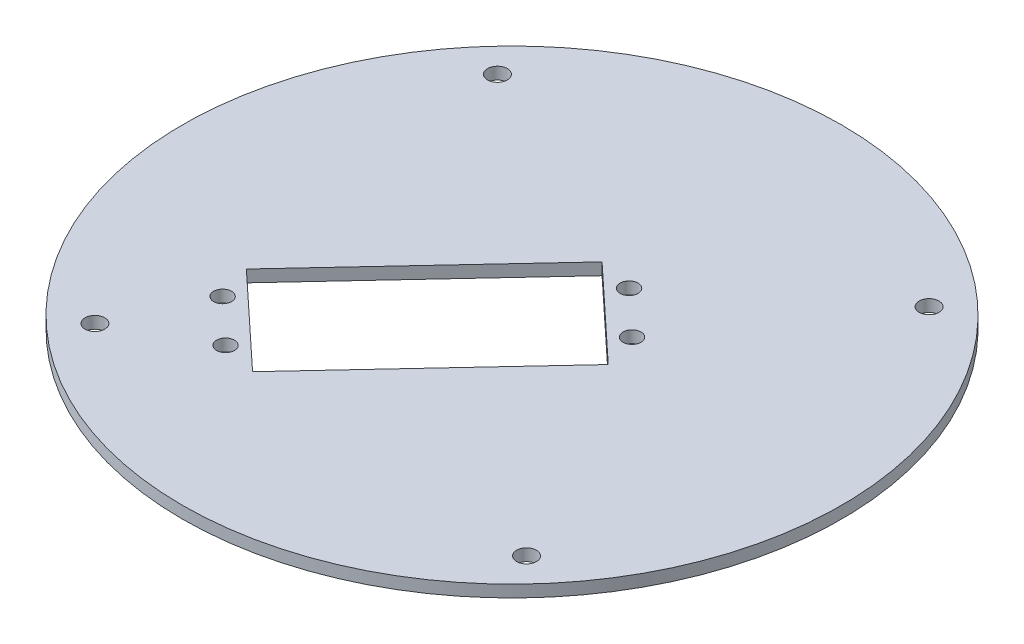
from build123d import *

# Parameters (mm, degrees)
SKETCH_1_R          = 55
EXTRUDE_1_DEPTH     = 2
SKETCH_2_R          = 1.65
CUT_EXTRUDE_1_DEPTH = 2
SKETCH_2_4_R        = 1.65
CUT_EXTRUDE_3_DEPTH = 2
SKETCH_3_R          = 1.5
CUT_EXTRUDE_4_DEPTH = 10


with BuildPart() as part:
    # 草图1 → 凸台-拉伸1 (new body)
    with BuildSketch(Plane(origin=(0, 0, 0), x_dir=(1, 0, 0), z_dir=(0, 1, 0))):
        Circle(SKETCH_1_R)
    extrude(amount=EXTRUDE_1_DEPTH)

    # 草图2 → 切除-拉伸1 (cut)
    with BuildSketch(Plane(origin=(0, 2, 0), x_dir=(1, 0, 0), z_dir=(0, 1, 0))):
        with Locations((36.016872787, -33.590882314)):
            Circle(SKETCH_2_R)
    extrude(amount=-CUT_EXTRUDE_1_DEPTH, mode=Mode.SUBTRACT)

    # 草图2<4> → 切除-拉伸3 (cut)
    with BuildSketch(Plane(origin=(0, 2, 0), x_dir=(1, 0, 0), z_dir=(0, 1, 0))):
        with Locations((-36.016872787, 33.590882314)):
            Circle(SKETCH_2_4_R)
        with Locations((33.590882314, 36.016872787)):
            Circle(SKETCH_2_4_R)
        with Locations((-33.590882314, -36.016872787)):
            Circle(SKETCH_2_4_R)
    extrude(amount=-CUT_EXTRUDE_3_DEPTH, mode=Mode.SUBTRACT)

    # 草图3 → 切除-拉伸4 (cut)
    with BuildSketch(Plane(origin=(0, 2, 0), x_dir=(1, 0, 0), z_dir=(0, 1, 0))):
        with Locations((-26.846179952, -21.454198237)):
            Circle(SKETCH_3_R)
        with Locations((-19.533109335, -28.274681956)):
            Circle(SKETCH_3_R)
        with Locations((5.892141898, 13.648540723)):
            Circle(SKETCH_3_R)
        with Locations((13.205212514, 6.828057004)):
            Circle(SKETCH_3_R)
        Polygon((-28.822223675, -15.509011007), (-0.176192057, 15.205885583), (15.181256238, 0.882869774), (-13.46477538, -29.832026816), align=None)
    extrude(amount=-CUT_EXTRUDE_4_DEPTH, mode=Mode.SUBTRACT)


solid = part.part
